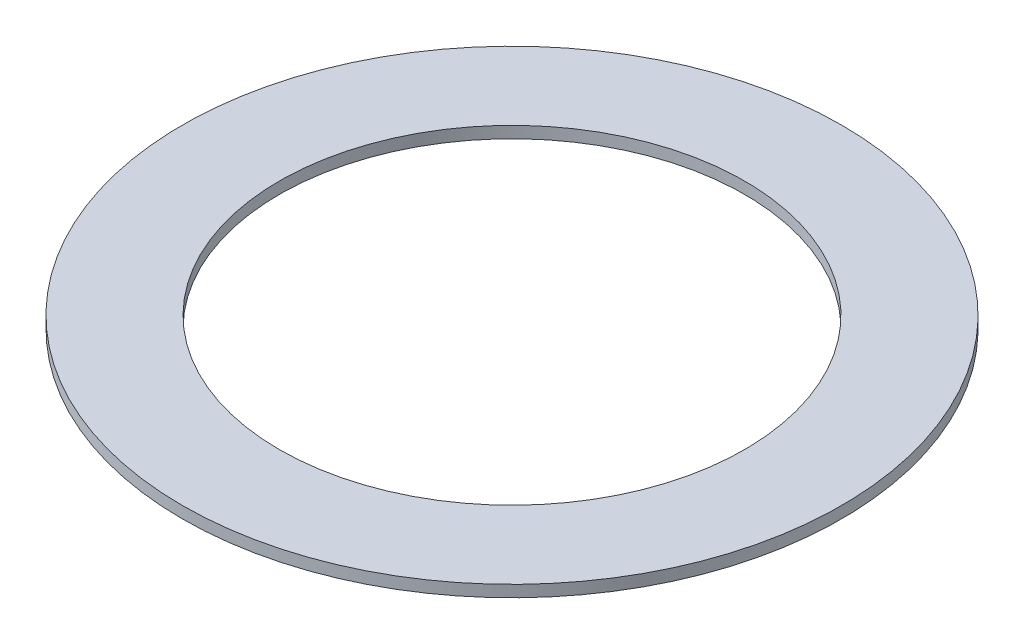
from build123d import *

# Parameters (mm, degrees)
SKETCH1_R           = 53.975
SKETCH1_R_2         = 38.1
BOSS_EXTRUDE1_DEPTH = 1.905


with BuildPart() as part:
    # Sketch1 → Boss-Extrude1 (new body)
    with BuildSketch(Plane(origin=(0, 0, 0), x_dir=(1, 0, 0), z_dir=(0, 1, 0))):
        Circle(SKETCH1_R)
        Circle(SKETCH1_R_2, mode=Mode.SUBTRACT)
    extrude(amount=BOSS_EXTRUDE1_DEPTH)


solid = part.part
